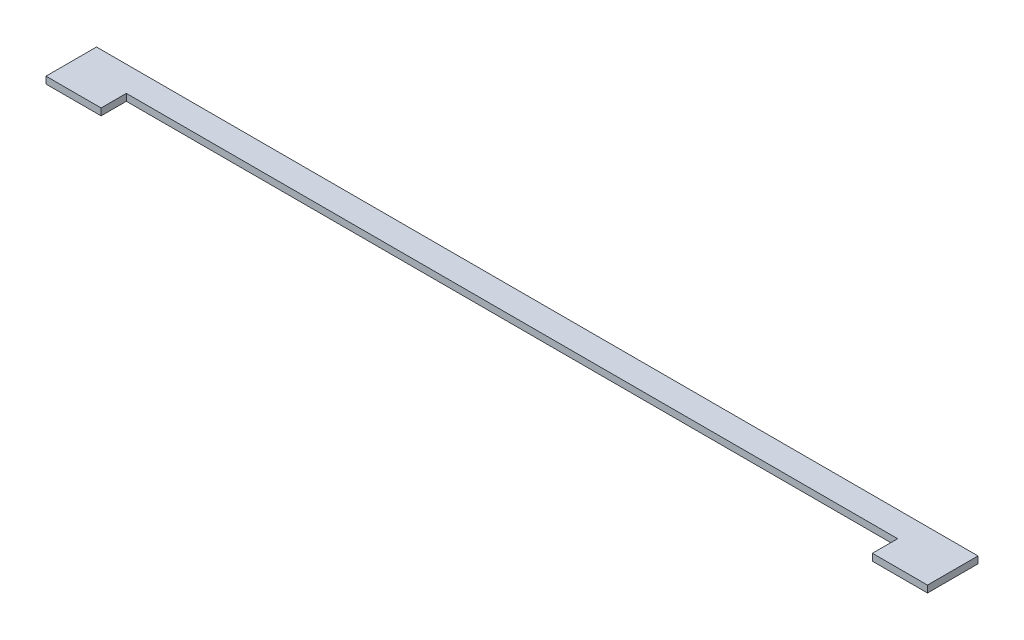
from build123d import *

# Parameters (mm, degrees)
SKETCH1_W           = 304.8
SKETCH1_H           = 139.7
SKETCH1_W_2         = 4876.8
BOSS_EXTRUDE1_DEPTH = 38.1


with BuildPart() as part:
    # Sketch1 → Boss-Extrude1 (new body)
    with BuildSketch(Plane(origin=(0, 0, 0), x_dir=(1, 0, 0), z_dir=(0, 1, 0))):
        with Locations((-4335.414005193, 58.576397217)):
            Rectangle(SKETCH1_W, SKETCH1_H)
        with Locations((-2049.414005193, 198.276397217)):
            Rectangle(SKETCH1_W_2, SKETCH1_H)
        with Locations((236.585994807, 58.576397217)):
            Rectangle(SKETCH1_W, SKETCH1_H)
    extrude(amount=BOSS_EXTRUDE1_DEPTH)


solid = part.part
